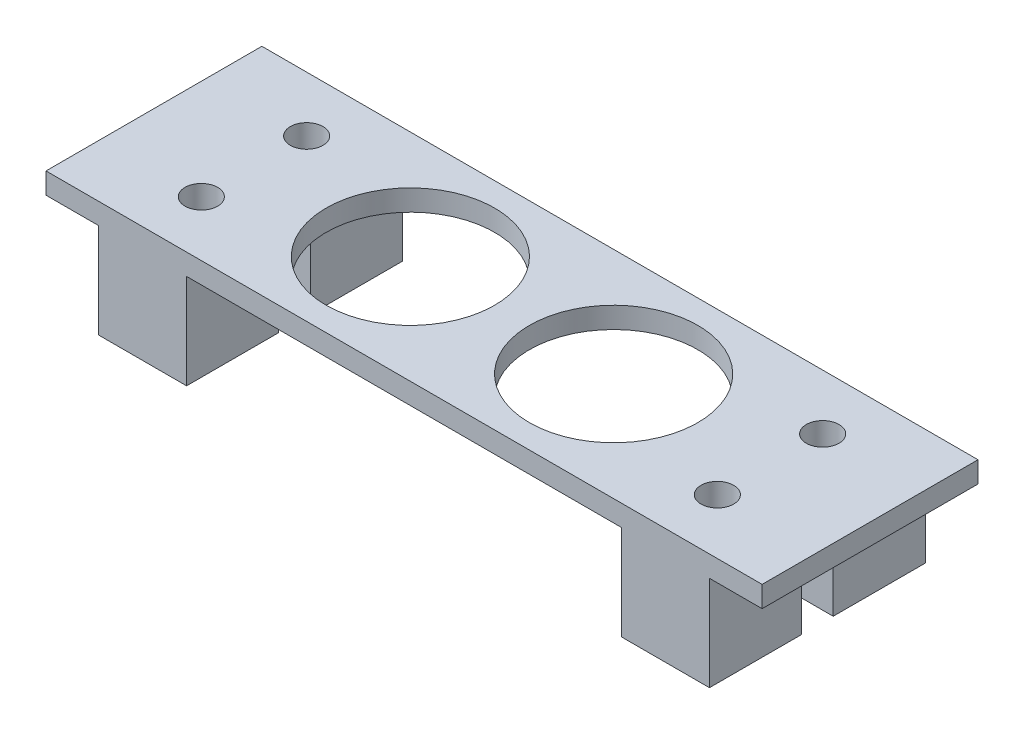
from build123d import *

# Parameters (mm, degrees)
SKETCH2_W           = 58
SKETCH2_H           = 20.5
SKETCH2_R           = 8
SKETCH2_R_2         = 1.55
BOSS_EXTRUDE1_DEPTH = 2
SKETCH3_W           = 8.35
SKETCH3_H           = 8.75
SKETCH3_R           = 1.55
BOSS_EXTRUDE2_DEPTH = 9
SKETCH4_W           = 5
SKETCH4_H           = 20.5
BOSS_EXTRUDE3_DEPTH = 2


with BuildPart() as part:
    # Sketch2 → Boss-Extrude1 (new body)
    with BuildSketch(Plane(origin=(0, 0, 0), x_dir=(1, 0, 0), z_dir=(0, 1, 0))):
        Rectangle(SKETCH2_W, SKETCH2_H)
        with Locations((-9.65, 0)):
            Circle(SKETCH2_R, mode=Mode.SUBTRACT)
        with Locations((-24.5, 5)):
            Circle(SKETCH2_R_2, mode=Mode.SUBTRACT)
        with Locations((-24.5, -5)):
            Circle(SKETCH2_R_2, mode=Mode.SUBTRACT)
        with Locations((24.5, 5)):
            Circle(SKETCH2_R_2, mode=Mode.SUBTRACT)
        with Locations((24.5, -5)):
            Circle(SKETCH2_R_2, mode=Mode.SUBTRACT)
        with Locations((9.65, 0)):
            Circle(SKETCH2_R, mode=Mode.SUBTRACT)
    extrude(amount=BOSS_EXTRUDE1_DEPTH)

    # Sketch3 → Boss-Extrude2 (add)
    with BuildSketch(Plane.XZ):
        with Locations((-24.825, 5.875)):
            Rectangle(SKETCH3_W, SKETCH3_H)
        with Locations((-24.5, 5)):
            Circle(SKETCH3_R, mode=Mode.SUBTRACT)
        with Locations((-24.825, -5.875)):
            Rectangle(SKETCH3_W, SKETCH3_H)
        with Locations((-24.5, -5)):
            Circle(SKETCH3_R, mode=Mode.SUBTRACT)
        with Locations((24.825, 5.875)):
            Rectangle(SKETCH3_W, SKETCH3_H)
        with Locations((24.5, 5)):
            Circle(SKETCH3_R, mode=Mode.SUBTRACT)
        with Locations((24.825, -5.875)):
            Rectangle(SKETCH3_W, SKETCH3_H)
        with Locations((24.5, -5)):
            Circle(SKETCH3_R, mode=Mode.SUBTRACT)
    extrude(amount=BOSS_EXTRUDE2_DEPTH)

    # Sketch4 → Boss-Extrude3 (add)
    with BuildSketch(Plane(origin=(0, 2, 0), x_dir=(1, 0, 0), z_dir=(0, 1, 0))):
        with Locations((-31.5, 0)):
            Rectangle(SKETCH4_W, SKETCH4_H)
        with Locations((31.5, 0)):
            Rectangle(SKETCH4_W, SKETCH4_H)
    extrude(amount=-BOSS_EXTRUDE3_DEPTH)


solid = part.part
